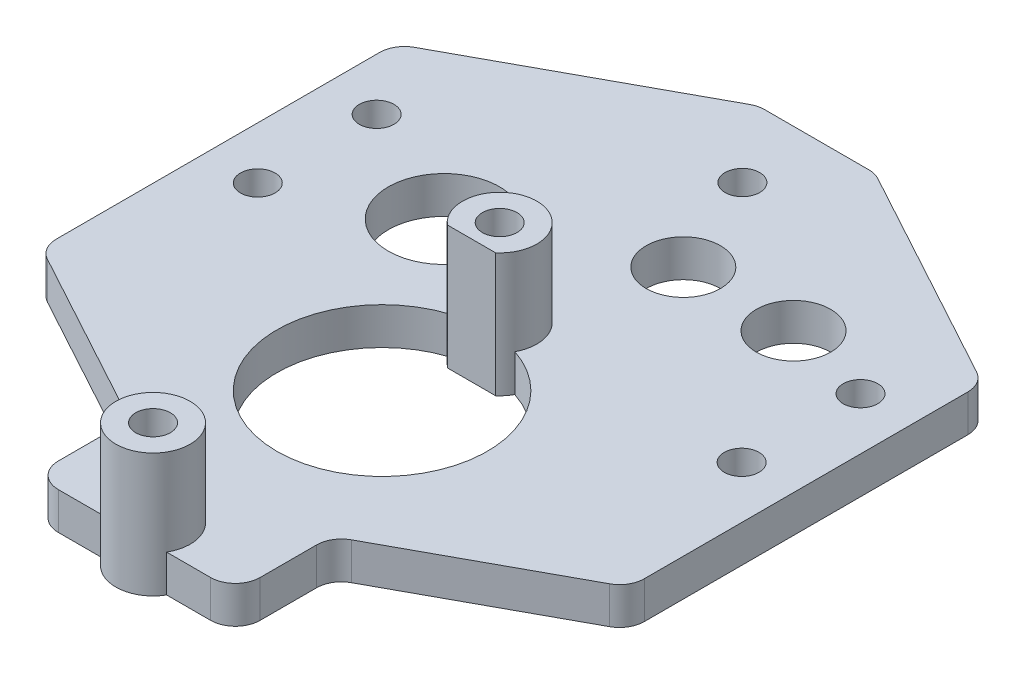
from build123d import *

# Parameters (mm, degrees)
SKETCH_1_R               = 8.5
SKETCH_1_R_2             = 4.5
SKETCH_1_R_3             = 3
SKETCH_1_R_4             = 1.4
EXTRUDE_1_DEPTH          = 3
FILLET_1_R               = 2
SKETCH_2_R               = 3
EXTRUDE_2_DEPTH          = 7
EXTRUDE_2_DEPTH_BACK     = 3
SKETCH_3_R               = 1.4
CUT_EXTRUDE_1_DEPTH      = 1
CUT_EXTRUDE_1_DEPTH_BACK = 11


with BuildPart() as part:
    # Эскиз1 → Бобышка-Вытянуть1 (new body)
    with BuildSketch(Plane(origin=(0, 0, 0), x_dir=(1, 0, 0), z_dir=(0, 1, 0))):
        Polygon((8.15, -20), (8.15, -12.25), (23.75, -3.757292419), (23.75, 24.742707581), (4.725, 35.1), (-4.725, 35.1), (-23.75, 24.742707581), (-23.75, -3.757292419), (-8.15, -12.25), (-8.15, -20), align=None)
        Circle(SKETCH_1_R, mode=Mode.SUBTRACT)
        with Locations((-9.5, 14.5)):
            Circle(SKETCH_1_R_2, mode=Mode.SUBTRACT)
        with Locations((3.53, 20.8)):
            Circle(SKETCH_1_R_3, mode=Mode.SUBTRACT)
        with Locations((12.43, 20.8)):
            Circle(SKETCH_1_R_3, mode=Mode.SUBTRACT)
        with Locations((19.54, 19.1)):
            Circle(SKETCH_1_R_4, mode=Mode.SUBTRACT)
        with Locations((19.54, 9.5)):
            Circle(SKETCH_1_R_4, mode=Mode.SUBTRACT)
        with Locations((-19.54, 19.1)):
            Circle(SKETCH_1_R_4, mode=Mode.SUBTRACT)
        with Locations((-19.54, 9.5)):
            Circle(SKETCH_1_R_4, mode=Mode.SUBTRACT)
        with Locations((0, 29.1)):
            Circle(SKETCH_1_R_4, mode=Mode.SUBTRACT)
    extrude(amount=EXTRUDE_1_DEPTH)

    # Скругление1
    fillet_1_edges = [part.edges().sort_by_distance(p)[0] for p in [
        (-8.15, 1.5, 20),
        (-8.15, 1.5, 12.25),
        (-23.75, 1.5, 3.757292419),
        (-23.75, 1.5, -24.742707581),
        (-4.725, 1.5, -35.1),
        (4.725, 1.5, -35.1),
        (23.75, 1.5, -24.742707581),
        (23.75, 1.5, 3.757292419),
        (8.15, 1.5, 12.25),
        (8.15, 1.5, 20),
    ]]
    fillet(fillet_1_edges, radius=FILLET_1_R)

    # Эскиз2 → Бобышка-Вытянуть2 (add, two sides)
    with BuildSketch(Plane(origin=(0, 3, 0), x_dir=(1, 0, 0), z_dir=(0, 1, 0))) as extrude_2_sk:
        with Locations((0, -18.5)):
            Circle(SKETCH_2_R)
        with BuildLine():
            Line((-1.949769217, 7.22), (1.949769217, 7.22))
            ThreePointArc((1.949769217, 7.22), (0, 12.5), (-1.949769217, 7.22))
        make_face()
    extrude(amount=EXTRUDE_2_DEPTH)
    extrude(extrude_2_sk.sketch, amount=-EXTRUDE_2_DEPTH_BACK)

    # Эскиз3 → Вырез-Вытянуть1 (cut, two sides)
    with BuildSketch(Plane(origin=(0, 10, 0), x_dir=(1, 0, 0), z_dir=(0, 1, 0))) as cut_extrude_1_sk:
        with Locations((0, 9.5)):
            Circle(SKETCH_3_R)
        with Locations((0, -18.5)):
            Circle(SKETCH_3_R)
    extrude(amount=CUT_EXTRUDE_1_DEPTH, mode=Mode.SUBTRACT)
    extrude(cut_extrude_1_sk.sketch, amount=-CUT_EXTRUDE_1_DEPTH_BACK, mode=Mode.SUBTRACT)


solid = part.part
